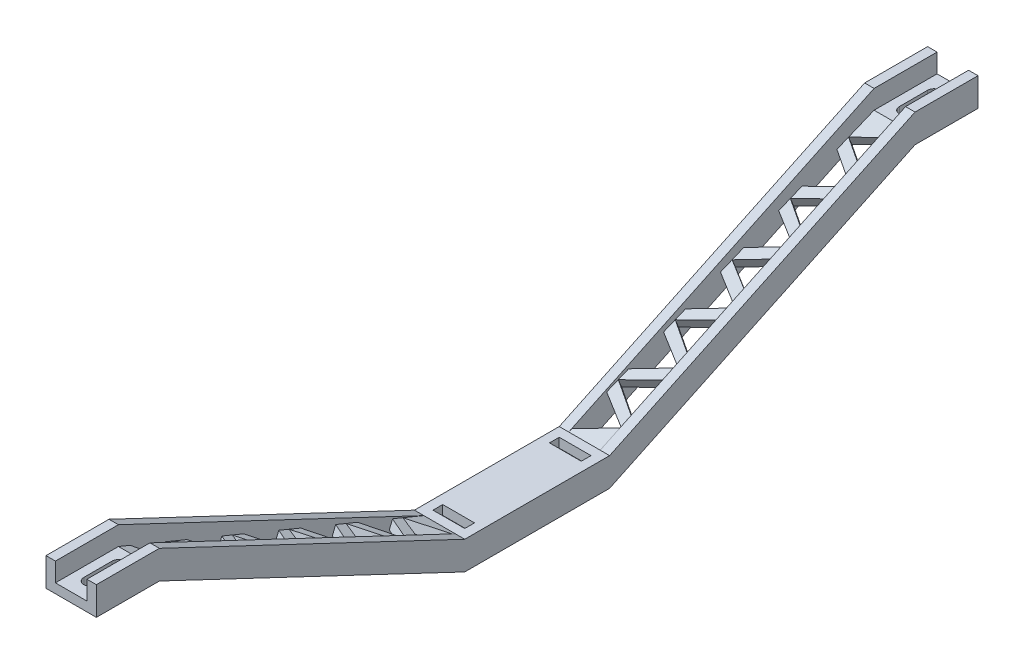
from build123d import *

# Parameters (mm, degrees)
BASESKETCH_W             = 16
BASESKETCH_H             = 300
BASE_DEPTH               = 46
SHAPESKETCH_OUTSIDE_W    = 362.786
SHAPESKETCH_OUTSIDE_H    = 108.786
SHAPE_DEPTH              = 17
SUPPORTR_DEPTH           = 3
SUPPORTL_START           = -16
SUPPORTL_DEPTH           = 3
CONNECTIONCENTERSKETCH_W = 10.1
CONNECTIONCENTERSKETCH_H = 3.1
CONNECTIONCENTER_DEPTH   = 10
WEIGHTL_DEPTH            = 57.736422329
WEIGHTR_DEPTH            = 57.736422329
CONNECTIONEND_DEPTH      = 7
CONNECTIONEND_DEPTH_BACK = 50
SHORTNERSKETCH_W         = 17.734474479
SHORTNERSKETCH_H         = 84.123631353
SHORTNERSKETCH_W_2       = 27.514011897
SHORTNERSKETCH_H_2       = 94.21863772
CUT_EXTRUDE1_DEPTH       = 17


with BuildPart() as part:
    # BaseSketch → Base (new body)
    with BuildSketch(Plane(origin=(0, 0, 0), x_dir=(1, 0, 0), z_dir=(0, 1, 0))):
        Rectangle(BASESKETCH_W, BASESKETCH_H)
    extrude(amount=BASE_DEPTH)

    # ShapeSketch outside → Shape (cut, through all)
    with BuildSketch(Plane(origin=(8, 0, 0), x_dir=(0, 0, -1), z_dir=(1, 0, 0))):
        with Locations((0, 23)):
            Rectangle(SHAPESKETCH_OUTSIDE_W, SHAPESKETCH_OUTSIDE_H)
        Polygon((-23, 3), (23, 3), (120, 43), (150, 43), (150, 46), (120, 46), (23, 6), (-23, 6), (-120, 46), (-150, 46), (-150, 43), (-120, 43), align=None, mode=Mode.SUBTRACT)
    extrude(amount=-SHAPE_DEPTH, mode=Mode.SUBTRACT)

    # SupportSketch → SupportR (add)
    with BuildSketch(Plane.ZY.offset(8)):
        Polygon((-150, 52), (-150, 43), (-120, 43), (-23, -3), (23, -3), (120, 43), (150, 43), (150, 52), (120, 52), (23, 6), (-23, 6), (-120, 52), align=None)
    extrude(amount=-SUPPORTR_DEPTH)

    # SupportSketch_3 → SupportL (add)
    with BuildSketch(Plane.ZY.offset(8).offset(SUPPORTL_START)):
        Polygon((-150, 52), (-150, 43), (-120, 43), (-23, -3), (23, -3), (120, 43), (150, 43), (150, 52), (120, 52), (23, 6), (-23, 6), (-120, 52), align=None)
    extrude(amount=SUPPORTL_DEPTH)

    # ConnectionCenterSketch → ConnectionCenter (cut, through all)
    with BuildSketch(Plane(origin=(0, 6, 0), x_dir=(1, 0, 0), z_dir=(0, 1, 0))):
        with Locations((0, -18.5)):
            Rectangle(CONNECTIONCENTERSKETCH_W, CONNECTIONCENTERSKETCH_H)
        with Locations((0, 18.5)):
            Rectangle(CONNECTIONCENTERSKETCH_W, CONNECTIONCENTERSKETCH_H)
    extrude(amount=-CONNECTIONCENTER_DEPTH, mode=Mode.SUBTRACT)

    # WeightLSketch → WeightL (cut, through all)
    with BuildSketch(Plane(origin=(0, -2.97810882, 1.228086111), x_dir=(1, 0, 0), z_dir=(0, 0.924480592, -0.38122911))):
        Polygon((-5, -124.474210145), (-5, -112.474210145), (5, -118.700707453), align=None)
        Polygon((5, -114.700707453), (5, -102.700707453), (-5, -108.927204761), align=None)
        Polygon((-5, -104.927204761), (-5, -92.927204761), (5, -99.153702069), align=None)
        Polygon((5, -95.153702069), (5, -83.153702069), (-5, -89.380199377), align=None)
        Polygon((5, -79.606696685), (-5, -85.380199377), (-5, -73.380199377), align=None)
        Polygon((5, -75.606696685), (5, -63.606696685), (-5, -69.833193994), align=None)
        Polygon((-5, -46.28618861), (-5, -34.28618861), (5, -40.512685918), align=None)
        Polygon((-5, -65.833193994), (-5, -53.833193994), (5, -60.059691302), align=None)
        Polygon((5, -56.059691302), (5, -44.059691302), (-5, -50.28618861), align=None)
        Polygon((5, -36.512685918), (5, -24.512685918), (-5, -30.739183226), align=None)
    extrude(amount=-WEIGHTL_DEPTH, mode=Mode.SUBTRACT)

    # WeightRSketch → WeightR (cut, through all)
    with BuildSketch(Plane(origin=(0, -2.97810882, -1.228086111), x_dir=(1, 0, 0), z_dir=(0, 0.924480592, 0.38122911))):
        Polygon((5, 125.474210145), (5, 113.474210145), (-5, 119.700707453), align=None)
        Polygon((-5, 115.700707453), (-5, 103.700707453), (5, 109.474210145), align=None)
        Polygon((5, 105.474210145), (5, 93.474210145), (-5, 99.700707453), align=None)
        Polygon((-5, 95.700707453), (-5, 83.700707453), (5, 89.927204761), align=None)
        Polygon((5, 85.927204761), (5, 73.927204761), (-5, 79.700707453), align=None)
        Polygon((-5, 75.700707453), (-5, 63.700707453), (5, 69.927204761), align=None)
        Polygon((5, 65.927204761), (5, 53.927204761), (-5, 60.153702069), align=None)
        Polygon((-5, 56.153702069), (-5, 44.153702069), (5, 50.380199377), align=None)
        Polygon((5, 46.380199377), (5, 34.380199377), (-5, 40.606696685), align=None)
        Polygon((-5, 36.606696685), (-5, 24.606696685), (5, 30.833193994), align=None)
    extrude(amount=-WEIGHTR_DEPTH, mode=Mode.SUBTRACT)

    # ConnectionEndSketch → ConnectionEnd (cut, two sides)
    with BuildSketch(Plane(origin=(0, 46, 0), x_dir=(1, 0, 0), z_dir=(0, 1, 0))) as connectionend_sk:
        with BuildLine():
            Line((2, 134), (2, 125))
            ThreePointArc((2, 125), (0, 123), (-2, 125))
            Line((-2, 125), (-2, 134))
            ThreePointArc((-2, 134), (0, 136), (2, 134))
        make_face()
        with BuildLine():
            Line((-2, -134), (-2, -125))
            ThreePointArc((-2, -125), (0, -123), (2, -125))
            Line((2, -125), (2, -134))
            ThreePointArc((2, -134), (0, -136), (-2, -134))
        make_face()
    extrude(amount=CONNECTIONEND_DEPTH, mode=Mode.SUBTRACT)
    extrude(connectionend_sk.sketch, amount=-CONNECTIONEND_DEPTH_BACK, mode=Mode.SUBTRACT)

    # ShortnerSketch → Cut-Extrude1 (cut, through all)
    with BuildSketch(Plane.ZY.offset(8)):
        with Locations((-148.86723724, 42.061815677)):
            Rectangle(SHORTNERSKETCH_W, SHORTNERSKETCH_H)
        with Locations((153.757005949, 47.10931886)):
            Rectangle(SHORTNERSKETCH_W_2, SHORTNERSKETCH_H_2)
    extrude(amount=-CUT_EXTRUDE1_DEPTH, mode=Mode.SUBTRACT)


solid = part.part
